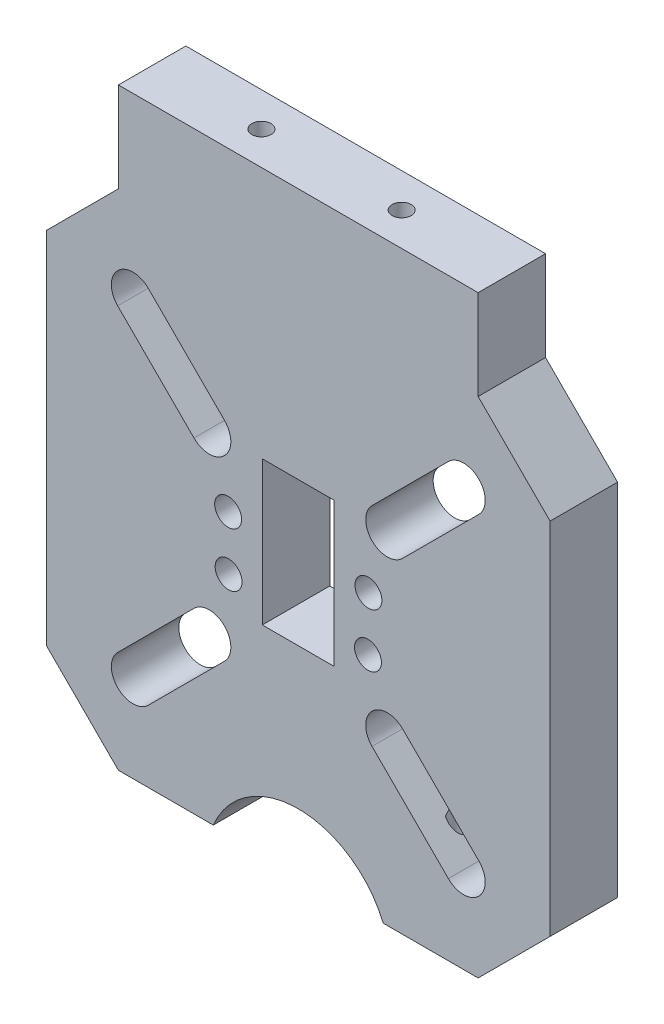
from build123d import *

# Parameters (mm, degrees)
SKETCH1_W                       = 71.12
SKETCH1_H                       = 71.12
EXTRUDE1_DEPTH                  = 9.525
SKETCH3_R                       = 3.048
CUT_EXTRUDE1_DEPTH              = 10.525
MIRROR3_COPY_1_SKETCH_R         = 3.048
MIRROR3_COPY_1_DEPTH            = 10.525
MIRROR3_COPY_2_SKETCH_R         = 3.048
MIRROR3_COPY_2_DEPTH            = 10.525
SKETCH5_W                       = 10.16
SKETCH5_H                       = 20.32
CUT_EXTRUDE4_DEPTH              = 10.525
SKETCH20_R                      = 13
CUT_EXTRUDE5_DEPTH              = 10.525
CHAMFER1_SIZE                   = 10.16
CHAMFER2_SIZE                   = 10.16
F_6_CLEARANCE_HOLE1_D           = 3.7973
CHAMFER3_SIZE                   = 10.16
SKETCH26_W                      = 50.8
SKETCH26_H                      = 9.525
EXTRUDE2_DEPTH                  = 12.7
F_6_32_TAPPED_HOLE4_D           = 2.7051
F_6_32_TAPPED_HOLE4_DEPTH       = 13.97
F_6_32_TAPPED_HOLE4_CBORE_D     = 3.5052
F_6_32_TAPPED_HOLE4_CBORE_DEPTH = 9.906
F_6_32_TAPPED_HOLE4_TIP         = 0.81269403
F_6_32_TAPPED_HOLE5_D           = 2.7051
F_6_32_TAPPED_HOLE5_DEPTH       = 13.97
F_6_32_TAPPED_HOLE5_TIP         = 0.81269403


with BuildPart() as part:
    # Sketch1 → Extrude1 (new body)
    with BuildSketch(Plane.XY):
        with Locations((-35.56, 35.56)):
            Rectangle(SKETCH1_W, SKETCH1_H)
    extrude(amount=EXTRUDE1_DEPTH)

    # Sketch3 → Cut-Extrude1 (cut, through all)
    with BuildSketch(Plane.XY.offset(9.525)):
        with Locations((-58.908665915, 58.908665915)):
            Circle(SKETCH3_R)
        with Locations((-48.132358569, 48.132358569)):
            Circle(SKETCH3_R)
        Polygon((-58.908665915, 58.908665915), (-56.753404446, 61.063927384), (-45.9770971, 50.287620039), (-50.287620039, 45.9770971), (-61.063927384, 56.753404446), align=None)
    cut_extrude1 = extrude(amount=-CUT_EXTRUDE1_DEPTH, mode=Mode.SUBTRACT)

    # Mirror1: Cut-Extrude1 across plane
    add(cut_extrude1.mirror(Plane.ZX.offset(35.56)), mode=Mode.SUBTRACT)

    # Mirror2: Cut-Extrude1 across plane
    add(cut_extrude1.mirror(Plane(origin=(-35.56, 0, 0), x_dir=(0, 0, 1), z_dir=(1, 0, 0))), mode=Mode.SUBTRACT)

    # Mirror3 copy 1 sketch → Mirror3 copy 1 (cut, through all)
    with BuildSketch(Plane(origin=(-71.12, 71.12, 9.525), x_dir=(-1, 0, 0), z_dir=(0, 0, 1))):
        with Locations((-58.908665915, 58.908665915)):
            Circle(MIRROR3_COPY_1_SKETCH_R)
        with Locations((-48.132358569, 48.132358569)):
            Circle(MIRROR3_COPY_1_SKETCH_R)
        Polygon((-58.908665915, 58.908665915), (-56.753404446, 61.063927384), (-45.9770971, 50.287620039), (-50.287620039, 45.9770971), (-61.063927384, 56.753404446), align=None)
    extrude(amount=-MIRROR3_COPY_1_DEPTH, mode=Mode.SUBTRACT)

    # Mirror3 copy 2 sketch → Mirror3 copy 2 (cut, through all)
    with BuildSketch(Plane(origin=(0, 71.12, 9.525), x_dir=(1, 0, 0), z_dir=(0, 0, 1))):
        with Locations((-58.908665915, -58.908665915)):
            Circle(MIRROR3_COPY_2_SKETCH_R)
        with Locations((-48.132358569, -48.132358569)):
            Circle(MIRROR3_COPY_2_SKETCH_R)
        Polygon((-58.908665915, -58.908665915), (-56.753404446, -61.063927384), (-45.9770971, -50.287620039), (-50.287620039, -45.9770971), (-61.063927384, -56.753404446), align=None)
    extrude(amount=-MIRROR3_COPY_2_DEPTH, mode=Mode.SUBTRACT)

    # Sketch5 → Cut-Extrude4 (cut, through all)
    with BuildSketch(Plane.XY.offset(9.525)):
        with Locations((-35.56, 38.1)):
            Rectangle(SKETCH5_W, SKETCH5_H)
    extrude(amount=-CUT_EXTRUDE4_DEPTH, mode=Mode.SUBTRACT)

    # Sketch20 → Cut-Extrude5 (cut, through all)
    with BuildSketch(Plane.XY.offset(9.525)):
        with Locations((-35.56, -5)):
            Circle(SKETCH20_R)
    extrude(amount=-CUT_EXTRUDE5_DEPTH, mode=Mode.SUBTRACT)

    # Chamfer1
    chamfer1_edges = [part.edges().sort_by_distance(p)[0] for p in [
        (-71.12, 71.12, 4.7625),
    ]]
    chamfer(chamfer1_edges, length=CHAMFER1_SIZE)

    # Chamfer2
    chamfer2_edges = [part.edges().sort_by_distance(p)[0] for p in [
        (0, 71.12, 4.7625),
    ]]
    chamfer(chamfer2_edges, length=CHAMFER2_SIZE)

    # #6 Clearance Hole1 (through all)
    with Locations(Plane(origin=(-45.4025, 31.75, 9.525), x_dir=(1, 0, 0), z_dir=(0, 0, 1))):
        with Locations((0, 0), (-0.0635, 7.619735412)):
            f_6_clearance_hole1 = Hole(F_6_CLEARANCE_HOLE1_D / 2)

    # Mirror11: #6 Clearance Hole1 across plane
    add(f_6_clearance_hole1.mirror(Plane(origin=(-35.56, 0, 0), x_dir=(0, 0, 1), z_dir=(1, 0, 0))), mode=Mode.SUBTRACT)

    # Chamfer3
    chamfer3_edges = [part.edges().sort_by_distance(p)[0] for p in [
        (0, 0, 4.7625),
        (-71.12, 0, 4.7625),
    ]]
    chamfer(chamfer3_edges, length=CHAMFER3_SIZE)

    # Sketch26 → Extrude2 (add)
    with BuildSketch(Plane(origin=(0, 71.12, 0), x_dir=(-1, 0, 0), z_dir=(0, 1, 0))):
        with Locations((35.56, 4.7625)):
            Rectangle(SKETCH26_W, SKETCH26_H)
    extrude(amount=EXTRUDE2_DEPTH)

    # #6-32 Tapped Hole4
    with Locations(Plane(origin=(-53.34, 0, 4.7625), x_dir=(-1, 0, 0), z_dir=(0, -1, 0))):
        with Locations((0, 0), (-35.56, 0)):
            CounterBoreHole(F_6_32_TAPPED_HOLE4_D / 2, F_6_32_TAPPED_HOLE4_CBORE_D / 2, F_6_32_TAPPED_HOLE4_CBORE_DEPTH, depth=F_6_32_TAPPED_HOLE4_DEPTH)
            with Locations((0, 0, -(F_6_32_TAPPED_HOLE4_DEPTH + F_6_32_TAPPED_HOLE4_TIP / 2))):  # 118° drill point
                Cone(0, F_6_32_TAPPED_HOLE4_D / 2, F_6_32_TAPPED_HOLE4_TIP, mode=Mode.SUBTRACT)

    # #6-32 Tapped Hole5
    with Locations(Plane(origin=(-45.466, 83.82, 4.826), x_dir=(1, 0, 0), z_dir=(0, 1, 0))):
        with Locations((0, 0), (19.812, 0)):
            Hole(F_6_32_TAPPED_HOLE5_D / 2, depth=F_6_32_TAPPED_HOLE5_DEPTH)
            with Locations((0, 0, -(F_6_32_TAPPED_HOLE5_DEPTH + F_6_32_TAPPED_HOLE5_TIP / 2))):  # 118° drill point
                Cone(0, F_6_32_TAPPED_HOLE5_D / 2, F_6_32_TAPPED_HOLE5_TIP, mode=Mode.SUBTRACT)


solid = part.part
